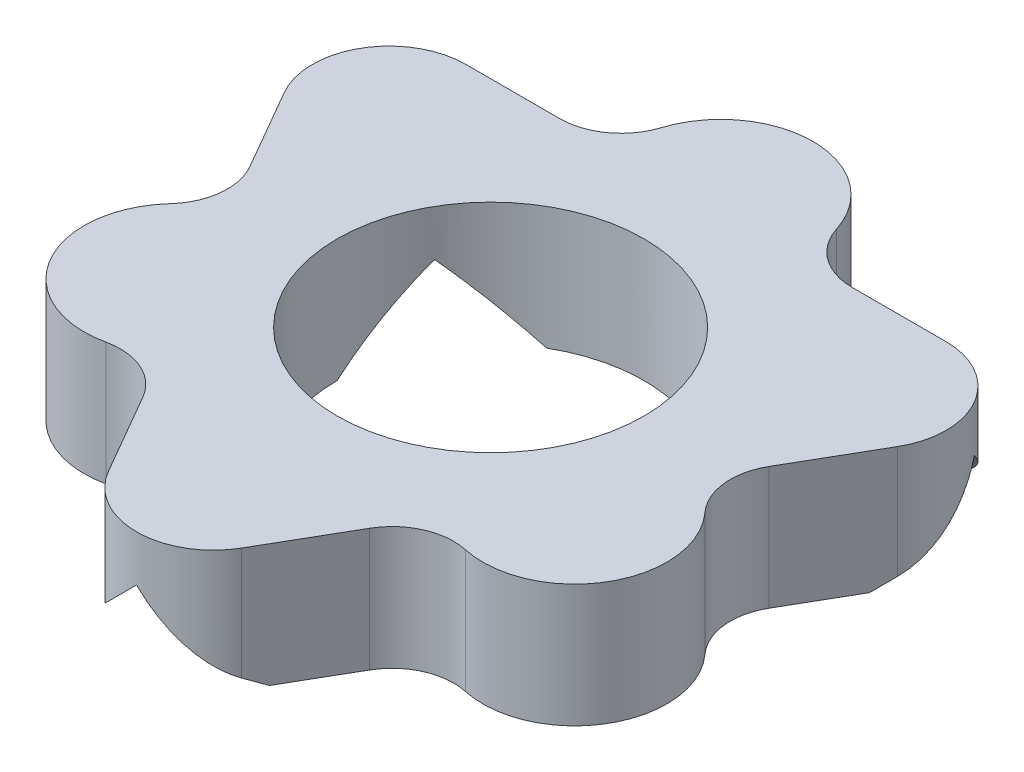
from build123d import *

# Parameters (mm, degrees)
SKETCH1_R      = 5
EXTRUDE1_DEPTH = 4
EXTRUDE4_START = 4.45086
EXTRUDE4_DEPTH = 7.205259
EXTRUDE5_START = 4.330127
EXTRUDE5_DEPTH = 7.205258
EXTRUDE6_START = 4.330127
EXTRUDE6_DEPTH = 7.205258


with BuildPart() as part:
    # Sketch1 → Extrude1 (new body)
    with BuildSketch(Plane(origin=(0, 0, 0), x_dir=(1, 0, 0), z_dir=(0, 1, 0))):
        with BuildLine():
            Line((-3.89089061, 3.146959138), (-2.360502052, 0.4962484))
            ThreePointArc((-2.360502052, 0.4962484), (-2.104118872, -0.718531203), (-2.613989574, -1.850544314))
            ThreePointArc((-2.613989574, -1.850544314), (-2.994220859, -5.370733384), (0.244467944, -6.801537968))
            ThreePointArc((0.244467944, -6.801537968), (1.479755407, -6.925983542), (2.403593813, -7.75540769))
            Line((2.403593813, -7.75540769), (3.933982371, -10.406118428))
            ThreePointArc((3.933982371, -10.406118428), (6.099045881, -11.656118428), (8.26410939, -10.406118428))
            Line((8.26410939, -10.406118428), (9.794497948, -7.75540769))
            ThreePointArc((9.794497948, -7.75540769), (10.718336354, -6.925983542), (11.953623817, -6.801537968))
            ThreePointArc((11.953623817, -6.801537968), (15.192312621, -5.370733384), (14.812081336, -1.850544314))
            ThreePointArc((14.812081336, -1.850544314), (14.302210633, -0.718531203), (14.558593813, 0.4962484))
            Line((14.558593813, 0.4962484), (16.088982371, 3.146959138))
            ThreePointArc((16.088982371, 3.146959138), (16.088982371, 5.646959138), (13.923918862, 6.896959138))
            Line((13.923918862, 6.896959138), (10.863141746, 6.896959138))
            ThreePointArc((10.863141746, 6.896959138), (9.68292016, 7.282314592), (8.9575034, 8.289882129))
            ThreePointArc((8.9575034, 8.289882129), (6.099045881, 10.379266616), (3.240588362, 8.289882129))
            ThreePointArc((3.240588362, 8.289882129), (2.515171602, 7.282314592), (1.334950016, 6.896959138))
            Line((1.334950016, 6.896959138), (-1.7258271, 6.896959138))
            ThreePointArc((-1.7258271, 6.896959138), (-3.89089061, 5.646959138), (-3.89089061, 3.146959138))
        make_face()
        with Locations((6.099045881, -0.120733384)):
            Circle(SKETCH1_R, mode=Mode.SUBTRACT)
    extrude(amount=EXTRUDE1_DEPTH)

    # GrooveSketch → Extrude4 (cut)
    with BuildSketch(Plane.XY.offset(EXTRUDE4_START)):
        Polygon((34.668922444, -26.069876563), (8.599045881, 0), (6.099045881, 2.5), (3.599045881, 0), (-22.470830682, -26.069876563), (-22.470830682, -99.806622573), (34.668922444, -99.806622573), align=None)
    extrude(amount=EXTRUDE4_DEPTH, mode=Mode.SUBTRACT)

    # Sketch9 → Extrude5 (cut)
    with BuildSketch(Plane(origin=(4.6265635, 0, 2.671147682), x_dir=(-0.5, 0, 0.866025404), z_dir=(-0.866025404, 0, -0.5)).offset(EXTRUDE5_START)):
        Polygon((32.223222882, -32.668187644), (-0.444964763, 0), (-2.944964763, 2.5), (-5.444964763, 0), (-38.113152407, -32.668187644), (-38.113152407, -125.067775694), (32.223222882, -125.067775694), align=None)
    extrude(amount=EXTRUDE5_DEPTH, mode=Mode.SUBTRACT)

    # Sketch10 → Extrude6 (cut)
    with BuildSketch(Plane(origin=(4.522005322, 0, -2.61078099), x_dir=(-0.5, 0, -0.866025404), z_dir=(0.866025404, 0, -0.5)).offset(EXTRUDE6_START)):
        Polygon((32.014106526, -32.668187644), (-0.654081118, 0), (-3.154081118, 2.5), (-5.654081118, 0), (-38.322268763, -32.668187644), (-38.322268763, -125.067775694), (32.014106526, -125.067775694), align=None)
    extrude(amount=EXTRUDE6_DEPTH, mode=Mode.SUBTRACT)


solid = part.part
